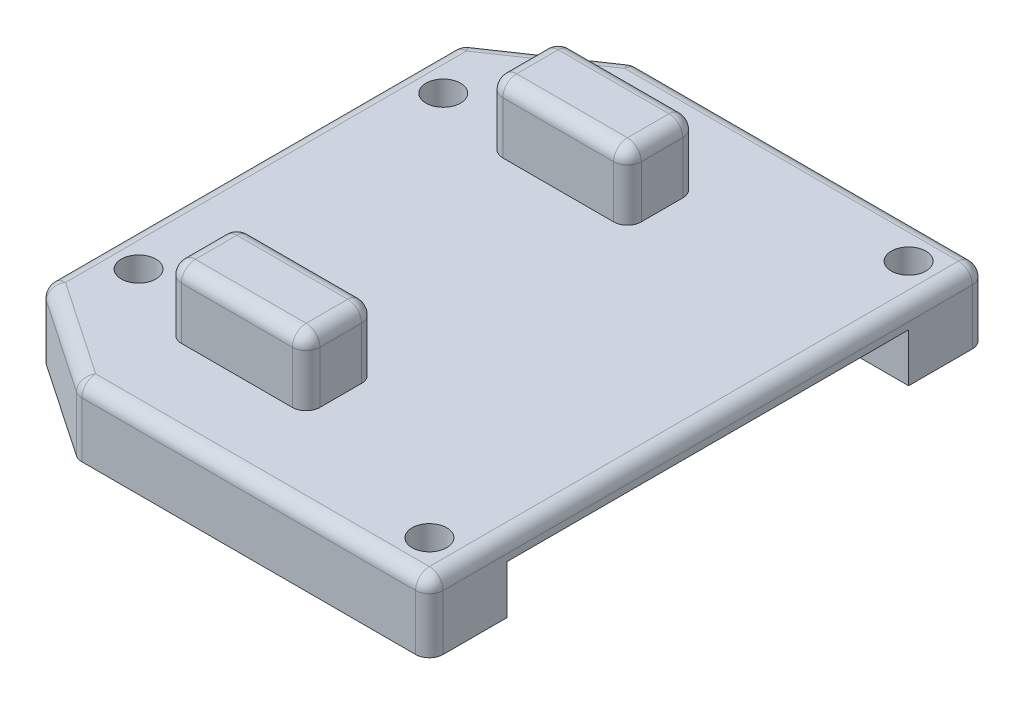
from build123d import *

# Parameters (mm, degrees)
SKETCH1_W           = 32.9
SKETCH1_H           = 40.2
BOSS_EXTRUDE1_DEPTH = 5
SKETCH2_W           = 29
SKETCH2_H           = 3.5
CUT_EXTRUDE1_DEPTH  = 27.3
SKETCH3_R           = 1.25
CUT_EXTRUDE2_DEPTH  = 6
SKETCH4_W           = 10
SKETCH4_H           = 5
BOSS_EXTRUDE2_DEPTH = 4.7625
CHAMFER1_SIZE       = 7.5
CHAMFER1_SIZE2      = 5.1
CHAMFER2_SIZE       = 5.1
CHAMFER2_SIZE2      = 7.5
FILLET1_R           = 1


with BuildPart() as part:
    # Sketch1 → Boss-Extrude1 (new body)
    with BuildSketch(Plane(origin=(0, 0, 0), x_dir=(1, 0, 0), z_dir=(0, 1, 0))):
        Rectangle(SKETCH1_W, SKETCH1_H)
    extrude(amount=BOSS_EXTRUDE1_DEPTH)

    # Sketch2 → Cut-Extrude1 (cut)
    with BuildSketch(Plane(origin=(16.45, 0, 0), x_dir=(0, 0, -1), z_dir=(1, 0, 0))):
        with Locations((0, 1.75)):
            Rectangle(SKETCH2_W, SKETCH2_H)
    extrude(amount=-CUT_EXTRUDE1_DEPTH, mode=Mode.SUBTRACT)

    # Sketch3 → Cut-Extrude2 (cut, through all)
    with BuildSketch(Plane(origin=(0, 5, 0), x_dir=(1, 0, 0), z_dir=(0, 1, 0))):
        with Locations((13.65, 17.3)):
            Circle(SKETCH3_R)
        with Locations((-13.65, 11)):
            Circle(SKETCH3_R)
    cut_extrude2 = extrude(amount=-CUT_EXTRUDE2_DEPTH, mode=Mode.SUBTRACT)

    # Sketch4 → Boss-Extrude2 (add)
    with BuildSketch(Plane(origin=(0, 5, 0), x_dir=(-1, 0, 0), z_dir=(0, 1, 0))):
        with Locations((3.45, -11.6)):
            Rectangle(SKETCH4_W, SKETCH4_H)
    boss_extrude2 = extrude(amount=BOSS_EXTRUDE2_DEPTH)

    # Mirror1: Cut-Extrude2, Boss-Extrude2 across plane
    add(cut_extrude2.mirror(Plane.XY), mode=Mode.SUBTRACT)
    add(boss_extrude2.mirror(Plane.XY))

    # Chamfer1
    chamfer1_edges = [part.edges().sort_by_distance(p)[0] for p in [
        (-16.45, 2.5, -20.1),
    ]]
    chamfer1_side = [part.faces().sort_by_distance(p)[0] for p in [
        (0, 2.5, -20.1),
    ]]
    chamfer(chamfer1_edges, length=CHAMFER1_SIZE, length2=CHAMFER1_SIZE2, reference=chamfer1_side[0])

    # Chamfer2
    chamfer2_edges = [part.edges().sort_by_distance(p)[0] for p in [
        (-16.45, 2.5, 20.1),
    ]]
    chamfer2_side = [part.faces().sort_by_distance(p)[0] for p in [
        (-16.45, 2.5, 2.55),
    ]]
    chamfer(chamfer2_edges, length=CHAMFER2_SIZE, length2=CHAMFER2_SIZE2, reference=chamfer2_side[0])

    # Fillet1
    fillet1_edges = [part.edges().sort_by_distance(p)[0] for p in [
        (1.55, 7.38125, -9.1),
        (1.55, 7.38125, -14.1),
        (16.45, 5, 0),
        (-8.45, 7.38125, -14.1),
        (-8.45, 7.38125, -9.1),
        (1.55, 9.7625, -11.6),
        (-3.45, 9.7625, -14.1),
        (-8.45, 9.7625, -11.6),
        (-3.45, 9.7625, -9.1),
        (1.55, 9.7625, 11.6),
        (1.55, 7.38125, 14.1),
        (-3.45, 9.7625, 9.1),
        (1.55, 7.38125, 9.1),
        (-8.45, 9.7625, 11.6),
        (-8.45, 7.38125, 9.1),
        (-3.45, 9.7625, 14.1),
        (-8.45, 7.38125, 14.1),
        (3.75, 5, -20.1),
        (-16.45, 5, 0),
        (-16.45, 2.5, -15),
        (-8.95, 2.5, -20.1),
        (-12.7, 5, -17.55),
        (16.45, 2.5, 20.1),
        (3.75, 5, 20.1),
        (-8.95, 2.5, 20.1),
        (16.45, 2.5, -20.1),
        (-16.45, 2.5, 15),
        (-12.7, 5, 17.55),
    ]]
    fillet(fillet1_edges, radius=FILLET1_R)


solid = part.part
